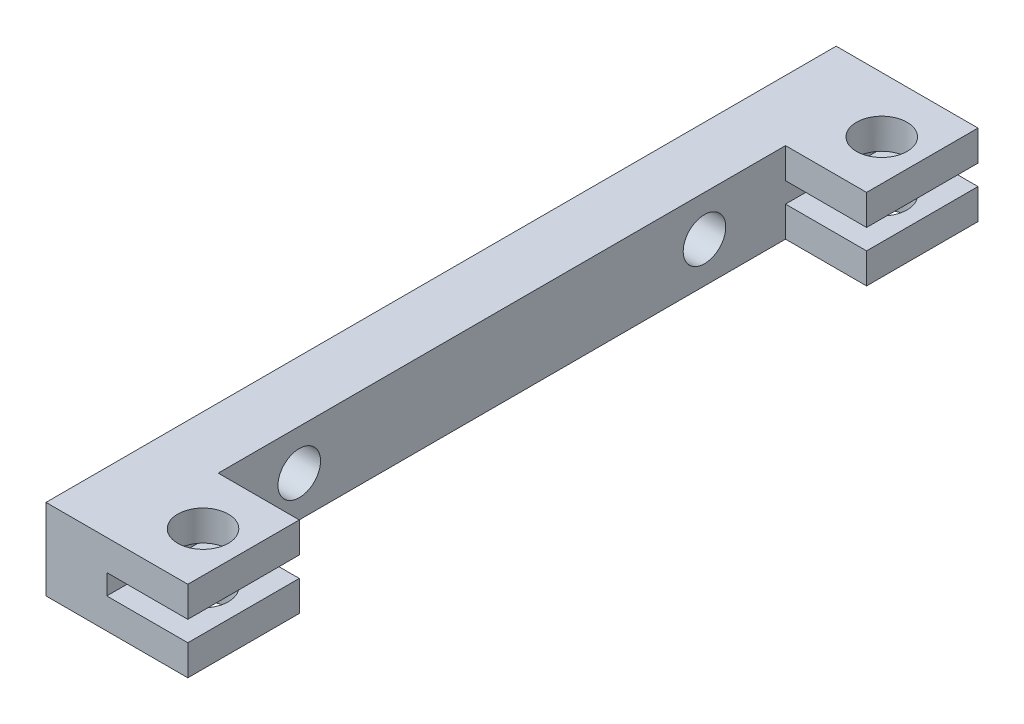
from build123d import *

# Parameters (mm, degrees)
EXTRUDE_1_DEPTH     = 78
SKETCH_2_W          = 8
SKETCH_2_H          = 56
CUT_EXTRUDE_1_DEPTH = 9
SKETCH_3_R          = 2.5
CUT_EXTRUDE_2_DEPTH = 9
HOLE_WIZARD_M5_1_D  = 4.2


with BuildPart() as part:
    # 草图1 → 凸台-拉伸1 (new body)
    with BuildSketch(Plane.XY):
        Polygon((-5441.39073995, 1449.788604117), (-5441.39073995, 1457.788604117), (-5427.39073995, 1457.788604117), (-5427.39073995, 1454.788604117), (-5435.39073995, 1454.788604117), (-5435.39073995, 1452.788604117), (-5427.39073995, 1452.788604117), (-5427.39073995, 1449.788604117), align=None)
    extrude(amount=EXTRUDE_1_DEPTH)

    # 草图2 → 切除-拉伸1 (cut, through all)
    with BuildSketch(Plane(origin=(0, 1457.788604117, 0), x_dir=(1, 0, 0), z_dir=(0, 1, 0))):
        with Locations((-5431.39073995, -39)):
            Rectangle(SKETCH_2_W, SKETCH_2_H)
    extrude(amount=-CUT_EXTRUDE_1_DEPTH, mode=Mode.SUBTRACT)

    # 草图3 → 切除-拉伸2 (cut, through all)
    with BuildSketch(Plane(origin=(0, 1457.788604117, 0), x_dir=(1, 0, 0), z_dir=(0, 1, 0))):
        with Locations((-5431.39073995, -72.5)):
            Circle(SKETCH_3_R)
        with Locations((-5431.39073995, -5.5)):
            Circle(SKETCH_3_R)
    extrude(amount=-CUT_EXTRUDE_2_DEPTH, mode=Mode.SUBTRACT)

    # M5 螺纹孔1 (through all)
    with Locations(Plane.ZY.offset(5441.39073995)):
        with Locations((59, 1453.788604117), (19, 1453.788604117)):
            Hole(HOLE_WIZARD_M5_1_D / 2)


solid = part.part
